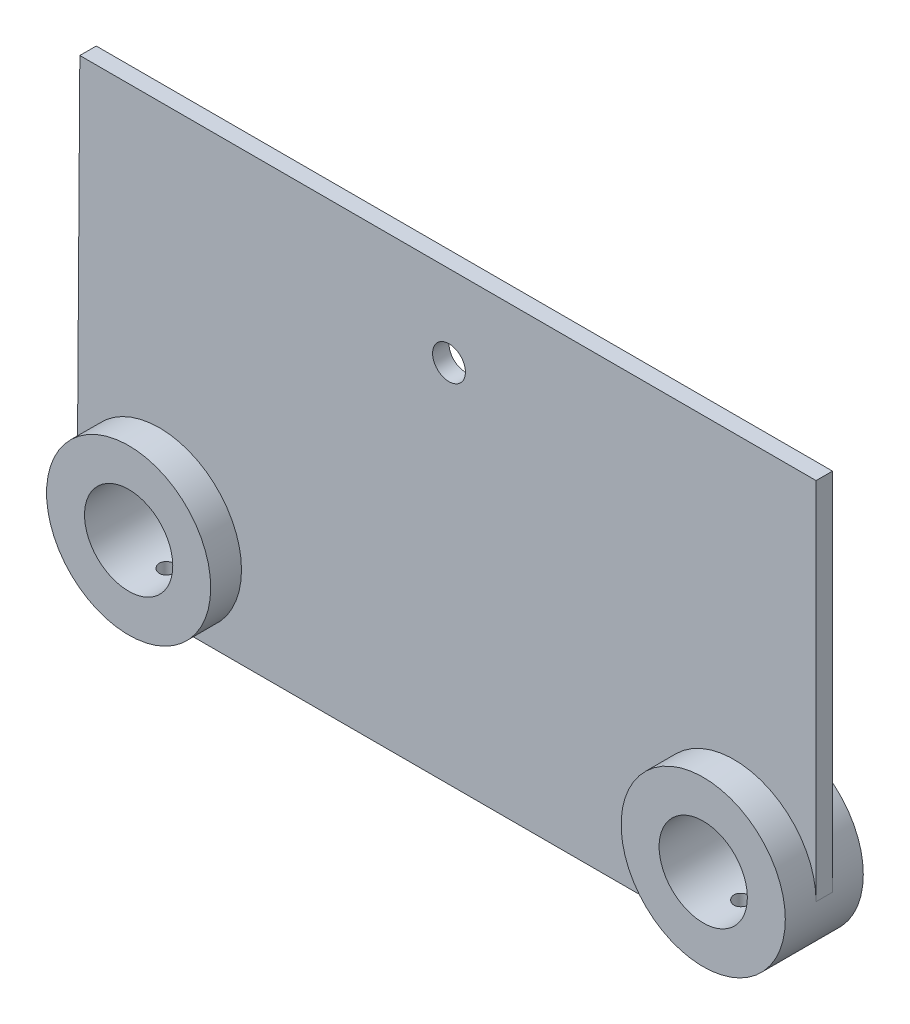
from build123d import *

# Parameters (mm, degrees)
SKETCH1_R                      = 10.75
BOSS_EXTRUDE1_DEPTH            = 2
CUT_EXTRUDE1_REACH             = 4
SKETCH2_R                      = 4
CUT_EXTRUDE1_DIRECTION_2_REACH = 4
SKETCH3_R                      = 20
SKETCH3_R_2                    = 10.75
BOSS_EXTRUDE2_DEPTH            = 9.5
SKETCH6_R                      = 2
CUT_EXTRUDE2_DEPTH             = 20


with BuildPart() as part:
    # Sketch1 → Boss-Extrude1 (new body, symmetric)
    with BuildSketch(Plane.XY):
        with BuildLine():
            Line((-70, -20), (70, -20))
            ThreePointArc((70, -20), (84.142135624, -14.142135624), (90, 0))
            Line((90, 0), (90, 88.85))
            Line((90, 88.85), (-89.389486479, 88.85))
            Line((-89.389486479, 88.85), (-90, 0))
            ThreePointArc((-90, 0), (-84.142135624, -14.142135624), (-70, -20))
        make_face()
        with Locations((70, 0)):
            Circle(SKETCH1_R, mode=Mode.SUBTRACT)
        with Locations((-70, 0)):
            Circle(SKETCH1_R, mode=Mode.SUBTRACT)
    extrude(amount=BOSS_EXTRUDE1_DEPTH, both=True)

    # Cut-Extrude1: up to this face of the body (flat: up to its plane)
    cut_extrude1_end = Plane(part.part.faces().sort_by_distance((0.130461416, 36.187362992, 2))[0])
    # Sketch2 → Cut-Extrude1 (cut, up to the picked face)
    with BuildSketch(Plane.XY, mode=Mode.PRIVATE) as cut_extrude1_sk1:
        with Locations((0.554740673, 69)):
            Circle(SKETCH2_R)
    cut_extrude1_tool1 = split(extrude(cut_extrude1_sk1.sketch, amount=CUT_EXTRUDE1_REACH, mode=Mode.PRIVATE), bisect_by=cut_extrude1_end, keep=Keep.BOTH, mode=Mode.PRIVATE)
    add(cut_extrude1_tool1.solids().sort_by_distance((0.554741, 69, 0))[0], mode=Mode.SUBTRACT)

    # Cut-Extrude1 direction 2: up to this face of the body (flat: up to its plane)
    cut_extrude1_direction_2_end = Plane(part.part.faces().sort_by_distance((0.130461416, 36.187362992, -2))[0])
    # Sketch2 → Cut-Extrude1 direction 2 (cut, up to the picked face)
    with BuildSketch(Plane.XY, mode=Mode.PRIVATE) as cut_extrude1_direction_2_sk1:
        with Locations((0.554740673, 69)):
            Circle(SKETCH2_R)
    cut_extrude1_direction_2_tool1 = split(extrude(cut_extrude1_direction_2_sk1.sketch, amount=-CUT_EXTRUDE1_DIRECTION_2_REACH, mode=Mode.PRIVATE), bisect_by=cut_extrude1_direction_2_end, keep=Keep.BOTH, mode=Mode.PRIVATE)
    add(cut_extrude1_direction_2_tool1.solids().sort_by_distance((0.554741, 69, 0))[0], mode=Mode.SUBTRACT)

    # Sketch3 → Boss-Extrude2 (add, symmetric)
    with BuildSketch(Plane.XY):
        with Locations((-70, 0)):
            Circle(SKETCH3_R)
        with Locations((-70, 0)):
            Circle(SKETCH3_R_2, mode=Mode.SUBTRACT)
        with Locations((70, 0)):
            Circle(SKETCH3_R)
        with Locations((70, 0)):
            Circle(SKETCH3_R_2, mode=Mode.SUBTRACT)
    extrude(amount=BOSS_EXTRUDE2_DEPTH, both=True)

    # Sketch6 → Cut-Extrude2 (cut)
    with BuildSketch(Plane(origin=(0, 0, 0), x_dir=(1, 0, 0), z_dir=(0, 1, 0))):
        with Locations((-70, 0)):
            Circle(SKETCH6_R)
        with Locations((70, 0)):
            Circle(SKETCH6_R)
    extrude(amount=-CUT_EXTRUDE2_DEPTH, mode=Mode.SUBTRACT)


solid = part.part
